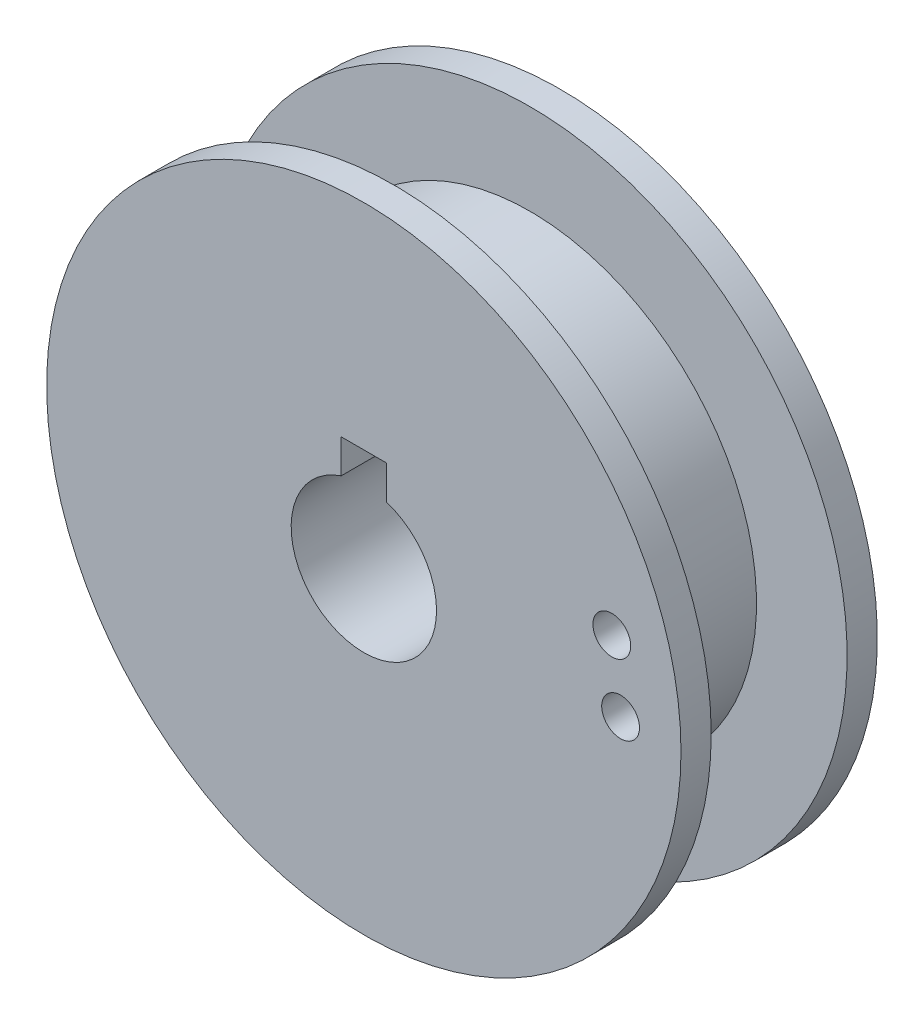
from build123d import *

# Parameters (mm, degrees)
SKETCH1_R       = 21
SIDE_1_DEPTH    = 2
SKETCH2_R       = 15
PULLEY_DEPTH    = 9
SKETCH3_R       = 21
SIDE_2_DEPTH    = 2
SKETCH4_R       = 4.8125
SHAFTHOLE_DEPTH = 13
SKETCH5_W       = 3
SKETCH5_H       = 4
KEYWAY_DEPTH    = 13
SKETCH6_R       = 1.25
CABLEHOLE_DEPTH = 2


with BuildPart() as part:
    # Sketch1 → Side 1 (new body)
    with BuildSketch(Plane.XY):
        Circle(SKETCH1_R)
    extrude(amount=SIDE_1_DEPTH)

    # Sketch2 → Pulley (add)
    with BuildSketch(Plane(origin=(0, 0, 0), x_dir=(-1, 0, 0), z_dir=(0, 0, -1))):
        Circle(SKETCH2_R)
    extrude(amount=PULLEY_DEPTH)

    # Sketch3 → Side 2 (add)
    with BuildSketch(Plane(origin=(0, 0, -9), x_dir=(-1, 0, 0), z_dir=(0, 0, -1))):
        Circle(SKETCH3_R)
    extrude(amount=SIDE_2_DEPTH)

    # Sketch4 → ShaftHole (cut)
    with BuildSketch(Plane(origin=(0, 0, -11), x_dir=(-1, 0, 0), z_dir=(0, 0, -1))):
        Circle(SKETCH4_R)
    extrude(amount=-SHAFTHOLE_DEPTH, mode=Mode.SUBTRACT)

    # Sketch5 → KeyWay (cut)
    with BuildSketch(Plane(origin=(0, 0, -11), x_dir=(-1, 0, 0), z_dir=(0, 0, -1))):
        with Locations((0, 4.8125)):
            Rectangle(SKETCH5_W, SKETCH5_H)
    extrude(amount=-KEYWAY_DEPTH, mode=Mode.SUBTRACT)

    # Sketch6 → CableHole (cut)
    with BuildSketch(Plane.XY.offset(2)):
        with Locations((17, 0)):
            Circle(SKETCH6_R)
        with Locations((16.420739047, 4.399923767)):
            Circle(SKETCH6_R)
    extrude(amount=-CABLEHOLE_DEPTH, mode=Mode.SUBTRACT)


solid = part.part
